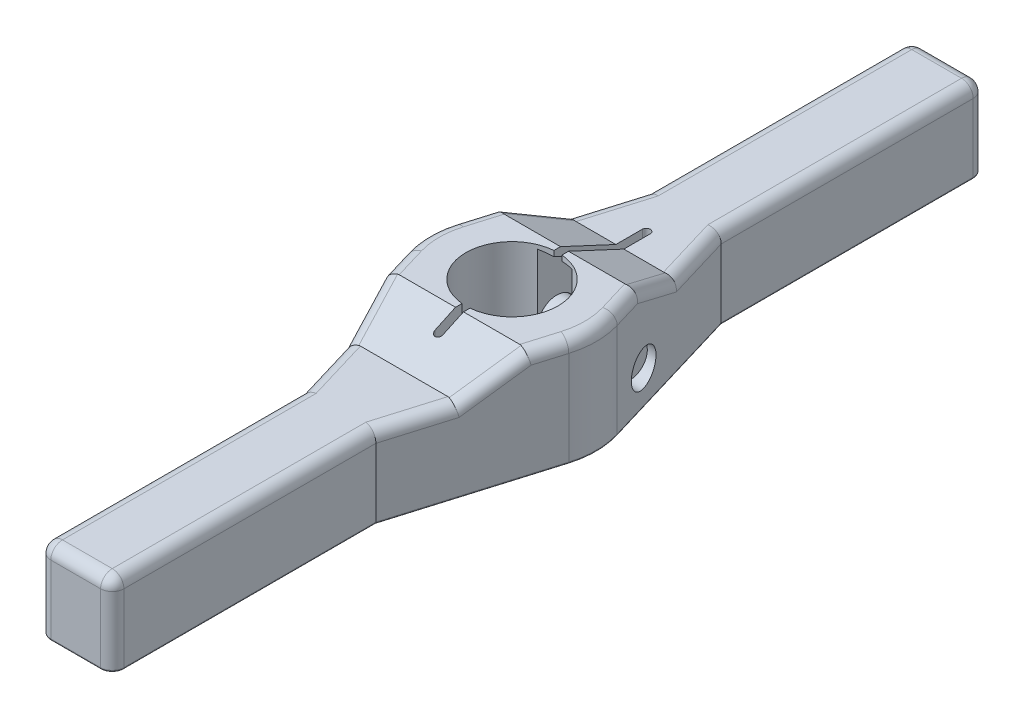
from build123d import *

# Parameters (mm, degrees)
SKETCH1_R                        = 19.06905
EXTRUDE1_DEPTH                   = 44.45
CUT_EXTRUDE1_DEPTH               = 35.925
CUT_EXTRUDE2_REACH               = 49.625
CUT_EXTRUDE2_OFFSET_FROM_SURFACE = 3.175
CUT_EXTRUDE3_DEPTH               = 45.45
SKETCH11_W                       = 30.226
SKETCH11_H                       = 108.966
EXTRUDE4_DEPTH                   = 33.782
EXTRUDE5_REACH                   = 35.782
EXTRUDE2_DEPTH                   = 10.0076
SKETCH7_R                        = 8.001
EXTRUDE3_DEPTH                   = 48.387
EXTRUDE6_REACH                   = 35.782
FILLET2_R                        = 4.826
FILLET1_R                        = 4.826
FILLET3_R                        = 0.762
CUT_EXTRUDE4_DEPTH               = 45.4500001


with BuildPart() as part:
    # Sketch1 → Extrude1 (new body)
    with BuildSketch(Plane(origin=(0, 0, 0), x_dir=(1, 0, 0), z_dir=(0, 1, 0))):
        with BuildLine():
            Line((-15.113, 71.374), (-33.46143944, 10.00438382))
            ThreePointArc((-33.46143944, 10.00438382), (-34.925, 0), (-33.46143944, -10.00438382))
            Line((-33.46143944, -10.00438382), (-15.113, -71.374))
            Line((-15.113, -71.374), (15.113, -71.374))
            Line((15.113, -71.374), (33.46143944, -10.00438382))
            ThreePointArc((33.46143944, -10.00438382), (34.925, 0), (33.46143944, 10.00438382))
            Line((33.46143944, 10.00438382), (15.113, 71.374))
            Line((15.113, 71.374), (-15.113, 71.374))
        make_face()
        with Locations(Location((0, 0, 0), (0, 0, 270))):  # turned: the seam where the file's is
            Circle(SKETCH1_R, mode=Mode.SUBTRACT)
    extrude(amount=EXTRUDE1_DEPTH)

    # Sketch2 → Cut-Extrude1 (cut, symmetric)
    with BuildSketch(Plane(origin=(0, 0, 0), x_dir=(0, 0, -1), z_dir=(1, 0, 0))):
        Polygon((21.699400172, 44.45), (44.577, 33.782), (71.374, 21.286353684), (71.374, 44.45), align=None)
    cut_extrude1 = extrude(amount=CUT_EXTRUDE1_DEPTH, both=True, mode=Mode.SUBTRACT)

    # Cut-Extrude2: up to this face of the body (flat: up to its plane, moved by the offset)
    cut_extrude2_end = Plane(part.part.faces().sort_by_distance((0, 34.140134728, -43.808977597))[0]).offset(-CUT_EXTRUDE2_OFFSET_FROM_SURFACE)
    # Sketch3 → Cut-Extrude2 (cut, up to the picked face)
    with BuildSketch(Plane.XZ, mode=Mode.PRIVATE) as cut_extrude2_sk1:
        with BuildLine():
            Line((-7.1374, -10.3124), (-7.1374, -50.0126))
            ThreePointArc((-7.1374, -50.0126), (0, -57.15), (7.1374, -50.0126))
            Line((7.1374, -50.0126), (7.1374, -10.3124))
            ThreePointArc((7.1374, -10.3124), (0, -3.175), (-7.1374, -10.3124))
        make_face()
    cut_extrude2_tool1 = split(extrude(cut_extrude2_sk1.sketch, amount=-CUT_EXTRUDE2_REACH, mode=Mode.PRIVATE), bisect_by=cut_extrude2_end, keep=Keep.BOTH, mode=Mode.PRIVATE)
    add(cut_extrude2_tool1.solids().sort_by(Axis((0, 0, -30.1625), (0, 1, 0)))[0], mode=Mode.SUBTRACT)

    # Sketch4 → Cut-Extrude3 (cut, through all)
    with BuildSketch(Plane.XZ):
        with BuildLine():
            Line((-1.651, 0), (-1.651, -55.499))
            ThreePointArc((-1.651, -55.499), (0, -57.15), (1.651, -55.499))
            Line((1.651, -55.499), (1.651, 0))
            Line((1.651, 0), (-1.651, 0))
        make_face()
    extrude(amount=-CUT_EXTRUDE3_DEPTH, mode=Mode.SUBTRACT)

    # Sketch11 → Extrude4 (add)
    with BuildSketch(Plane.XZ):
        with Locations((0, -125.857)):
            Rectangle(SKETCH11_W, SKETCH11_H)
    extrude4 = extrude(amount=-EXTRUDE4_DEPTH)

    # Extrude5: up to this face of the body (flat: up to its plane)
    extrude5_end = Plane(part.part.faces().sort_by_distance((21.755047075, 32.957943252, -46.3441954))[0])
    # Sketch12 → Extrude5 (add, up to the picked face)
    with BuildSketch(Plane(origin=(0, 33.782, 0), x_dir=(1, 0, 0), z_dir=(0, 1, 0)), mode=Mode.PRIVATE) as extrude5_sk1:
        with BuildLine():
            Line((-1.651, 44.577), (-23.124833254, 44.577))
            Line((-23.124833254, 44.577), (-15.113, 71.374))
            Line((-15.113, 71.374), (15.113, 71.374))
            Line((15.113, 71.374), (23.124833254, 44.577))
            Line((23.124833254, 44.577), (1.651, 44.577))
            Line((1.651, 44.577), (1.651, 55.499))
            ThreePointArc((1.651, 55.499), (0, 57.15), (-1.651, 55.499))
            Line((-1.651, 55.499), (-1.651, 44.577))
        make_face()
    extrude5_tool1 = split(extrude(extrude5_sk1.sketch, amount=-EXTRUDE5_REACH, mode=Mode.PRIVATE), bisect_by=extrude5_end, keep=Keep.BOTH, mode=Mode.PRIVATE)
    add(extrude5_tool1.solids().sort_by(Axis((0, 33.782, -57.299912), (0, -1, 0)))[0])

    # Sketch5 → Cut-Revolve1 (revolve, cut)
    with BuildSketch(Plane.XY.offset(-25.629), mode=Mode.PRIVATE) as cut_revolve1_sk:
        Polygon((-34.925, 31.7373), (-25.3492, 31.7373), (-25.3492, 22.4028), (7.1374, 22.4028), (7.1374, 21.5392), (33.46143944, 21.5392), (33.46143944, 14.2748), (-34.925, 14.2748), align=None)
    revolve(cut_revolve1_sk.sketch.rotate(Axis((-30.107344341, 14.2748, -25.629), (1, 0, 0)), 90), axis=Axis((-30.107344341, 14.2748, -25.629), (1, 0, 0)), mode=Mode.SUBTRACT)  # turned: the seam where the file's is

    # Sketch6 → Extrude2 (add)
    with BuildSketch(Plane.ZY.offset(25.3492)):
        Polygon((-11.770861489, 14.2748), (-18.699930744, 26.2763), (-32.558069256, 26.2763), (-39.487138511, 14.2748), (-32.558069256, 2.2733), (-18.699930744, 2.2733), align=None)
    extrude(amount=EXTRUDE2_DEPTH)

    # Sketch7 → Extrude3 (add)
    with BuildSketch(Plane.ZY.offset(25.3492)):
        with Locations(Location((-25.629, 14.2748, 0), (0, 0, 6.717974343))):  # turned: the seam where the file's is
            Circle(SKETCH7_R)
    extrude(amount=-EXTRUDE3_DEPTH)

    # Sketch8 → Cut-Revolve2 (revolve, cut)
    with BuildSketch(Plane.XY.offset(-25.629), mode=Mode.PRIVATE) as cut_revolve2_sk:
        Polygon((-35.3568, 2.2733), (-35.3568, -0.9017), (-33.523712895, -0.9017), align=None)
    revolve(cut_revolve2_sk.sketch.rotate(Axis((-5.551302264, 14.2748, -25.629), (-1, 0, 0)), 96.717974343), axis=Axis((-5.551302264, 14.2748, -25.629), (-1, 0, 0)), mode=Mode.SUBTRACT)  # turned: the seam where the file's is

    # Mirror1: Cut-Extrude1 across plane
    add(cut_extrude1.mirror(Plane.XY), mode=Mode.SUBTRACT)

    # Mirror2: Extrude4 across plane
    add(extrude4.mirror(Plane.XY))

    # Sketch16 → Extrude6 (add, up to next)
    with BuildSketch(Plane(origin=(0, 33.782, 0), x_dir=(1, 0, 0), z_dir=(0, 1, 0)), mode=Mode.PRIVATE) as extrude6_sk1:
        Polygon((15.113, -71.374), (23.124833254, -44.577), (-23.124833254, -44.577), (-15.113, -71.374), align=None)
    extrude6_tool1 = extrude(extrude6_sk1.sketch, amount=-EXTRUDE6_REACH, mode=Mode.PRIVATE) - part.part
    add(extrude6_tool1.solids().sort_by_distance((0, 33.782, 57.03972))[0])

    # Fillet2
    fillet2_edges = [part.edges().sort_by_distance(p)[0] for p in [
        (-15.113, 16.891, 180.34),
        (15.113, 16.891, 180.34),
        (-15.113, 16.891, -180.34),
        (15.113, 16.891, -180.34),
    ]]
    fillet(fillet2_edges, radius=FILLET2_R)

    # Fillet1
    fillet1_edges = [part.edges().sort_by_distance(p)[0] for p in [
        (34.925, 44.45, 0),
        (26.544833908, 39.116, -33.138200086),
        (19.118916627, 33.782, -57.9755),
        (-19.118916627, 33.782, -57.9755),
        (31.713137001, 44.45, -15.851891996),
        (-26.544833908, 39.116, 33.138200086),
        (31.713137001, 44.45, 15.851891996),
        (-34.925, 44.45, 0),
        (-15.113, 33.782, 123.444),
        (26.544833908, 39.116, 33.138200086),
        (19.118916627, 33.782, 57.9755),
        (-19.118916627, 33.782, 57.9755),
        (-31.713137001, 44.45, 15.851891996),
        (15.113, 33.782, 123.444),
        (0, 33.782, 180.34),
        (-31.713137001, 44.45, -15.851891996),
        (0, 33.782, -180.34),
        (15.113, 33.782, -123.444),
        (-26.544833908, 39.116, -33.138200086),
        (-15.113, 33.782, -123.444),
    ]]
    fillet(fillet1_edges, radius=FILLET1_R)

    # Fillet3
    fillet3_edges = [part.edges().sort_by_distance(p)[0] for p in [
        (-32.62932093, 0, -12.787552043),
        (-15.113, 0, 123.444),
        (15.113, 0, 123.444),
        (0, 0, -180.34),
        (15.113, 0, -123.444),
        (0, 0, 180.34),
        (-13.699497326, 0, -178.926497326),
        (13.699497326, 0, -178.926497326),
        (-13.699497326, 0, 178.926497326),
        (13.699497326, 0, 178.926497326),
        (-24.28721972, 0, 40.68919191),
        (-34.925, 0, 0),
        (-20.447851889, 0, -53.530639867),
        (24.28721972, 0, -40.68919191),
        (34.925, 0, 0),
        (-15.113, 0, -123.444),
        (24.28721972, 0, 40.68919191),
    ]]
    fillet(fillet3_edges, radius=FILLET3_R)

    # Sketch17 → Cut-Extrude4 (cut, through all)
    with BuildSketch(Plane(origin=(0, 44.45, 0), x_dir=(1, 0, 0), z_dir=(0, 1, 0))):
        with BuildLine():
            Line((-1.651, 0), (-1.651, -30.099))
            ThreePointArc((-1.651, -30.099), (0, -31.75), (1.651, -30.099))
            Line((1.651, -30.099), (1.651, 0))
            Line((1.651, 0), (-1.651, 0))
        make_face()
    extrude(amount=-CUT_EXTRUDE4_DEPTH, mode=Mode.SUBTRACT)


solid = part.part
